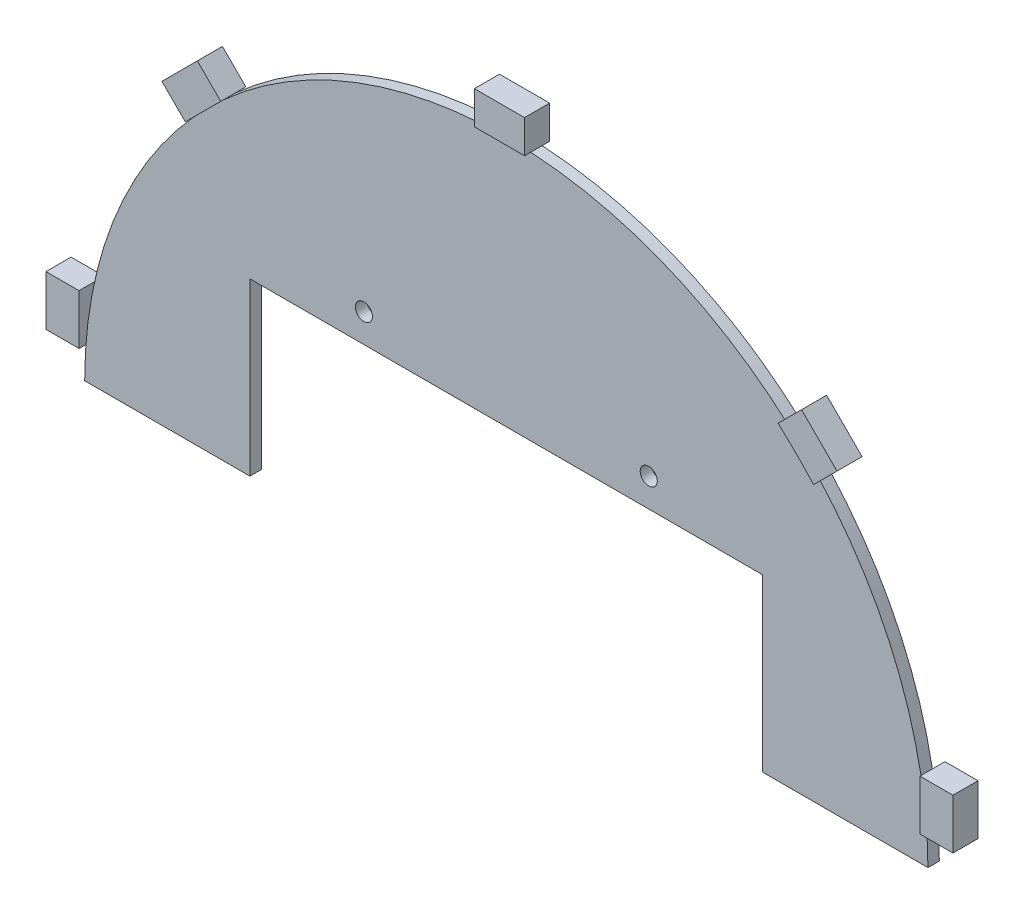
from build123d import *

# Parameters (mm, degrees)
ESQUISSE3_R             = 1.5
BOSS_EXTRU_1_DEPTH      = 2
BOSS_EXTRU_6_DEPTH      = 3.2
BOSS_EXTRU_6_DEPTH_BACK = 1.2
ESQUISSE3_3_W           = 5.8
ESQUISSE3_3_H           = 8.8
ESQUISSE3_3_W_2         = 8.8
ESQUISSE3_3_H_2         = 5.8


with BuildPart() as part:
    # Esquisse3 → Boss.-Extru.1 (new body)
    with BuildSketch(Plane.XY):
        with BuildLine():
            ThreePointArc((-73.78780387, 5.6), (-73.946931939, 2.802009422), (-74, 0))
            Line((-74, 0), (-45, 0))
            Line((-45, 0), (-45, 30))
            Line((-45, 30), (45, 30))
            Line((45, 30), (45, 0))
            Line((45, 0), (74, 0))
            ThreePointArc((74, 0), (73.946931939, 2.802009422), (73.78780387, 5.6))
            ThreePointArc((73.78780387, 5.6), (67.971162967, 29.256127647), (54.788343562, 49.741706945))
            Line((54.788343562, 49.741706945), (49.741706945, 54.788343562))
            ThreePointArc((49.741706945, 54.788343562), (26.661419471, 69.030201447), (0, 74))
            ThreePointArc((0, 74), (-26.514147167, 69.086901798), (-49.507575178, 55))
            Line((-49.507575178, 55), (-52.030150983, 52.5))
            Line((-52.030150983, 52.5), (-54.787353008, 49.742797975))
            ThreePointArc((-54.787353008, 49.742797975), (-67.970871665, 29.256804425), (-73.78780387, 5.6))
        make_face()
        with Locations((-25, 35)):
            Circle(ESQUISSE3_R, mode=Mode.SUBTRACT)
        with Locations((25, 35)):
            Circle(ESQUISSE3_R, mode=Mode.SUBTRACT)
    extrude(amount=BOSS_EXTRU_1_DEPTH)

    # Esquisse3_3 → Boss.-Extru.6 (add, two sides: drawn at the far end of the back side and taken through both)
    with BuildSketch(Plane.XY.offset(-BOSS_EXTRU_6_DEPTH_BACK)):
        with Locations((-76.68780387, 10)):
            Rectangle(ESQUISSE3_3_W, ESQUISSE3_3_H)
        with Locations((0, 76.9)):
            Rectangle(ESQUISSE3_3_W_2, ESQUISSE3_3_H_2)
        with Locations((76.68780387, 10)):
            Rectangle(ESQUISSE3_3_W, ESQUISSE3_3_H)
        Polygon((-48.918881146, 55.611269837), (-53.020100477, 59.712489168), (-59.242640151, 53.489949494), (-55.14142082, 49.388730163), align=None)
        with BuildLine():
            Line((48.918780669, 55.611269837), (49.741706945, 54.788343562))
            ThreePointArc((49.741706945, 54.788343562), (52.325901808, 52.325901808), (54.788343562, 49.741706945))
            Line((54.788343562, 49.741706945), (55.141320344, 49.388730163))
            Line((55.141320344, 49.388730163), (59.242539674, 53.489949494))
            Line((59.242539674, 53.489949494), (53.02, 59.712489168))
            Line((53.02, 59.712489168), (48.918780669, 55.611269837))
        make_face()
    extrude(amount=BOSS_EXTRU_6_DEPTH + BOSS_EXTRU_6_DEPTH_BACK)


with BuildPart() as boss_extru_6_piece_1:
    # of the separate pieces the step leaves, piece 1, a body of its own (boss_extru_6_pieces)
    add(part.part.solids().sort_by_distance((-52.030150983, 52.5, 2))[0])


with BuildPart() as boss_extru_6_piece_2:
    # of the separate pieces the step leaves, piece 2, a body of its own (boss_extru_6_pieces)
    add(part.part.solids().sort_by_distance((-79.58780387, 5.6, 3.2))[0])


with BuildPart() as boss_extru_6_piece_3:
    # of the separate pieces the step leaves, piece 3, a body of its own (boss_extru_6_pieces)
    add(part.part.solids().sort_by_distance((73.78780387, 14.4, 3.2))[0])


with BuildPart() as boss_extru_6_piece_4:
    # of the separate pieces the step leaves, piece 4, a body of its own (boss_extru_6_pieces)
    add(part.part.solids().sort_by_distance((-4.4, 74, 3.2))[0])


with BuildPart() as boss_extru_6_piece_5:
    # of the separate pieces the step leaves, piece 5, a body of its own (boss_extru_6_pieces)
    add(part.part.solids().sort_by_distance((54.788343562, 49.741706945, 3.2))[0])


solid = Compound([boss_extru_6_piece_1.part, boss_extru_6_piece_2.part, boss_extru_6_piece_3.part, boss_extru_6_piece_4.part, boss_extru_6_piece_5.part])
